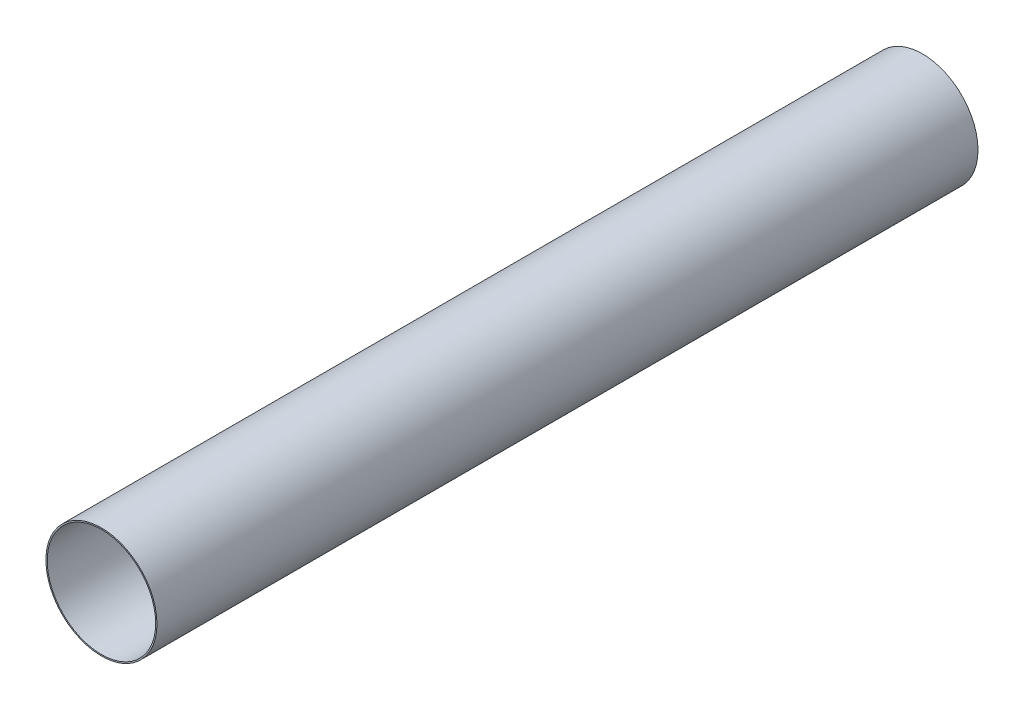
from build123d import *

# Parameters (mm, degrees)
SKETCH1_R           = 84.55
SKETCH1_R_2         = 82.55
BOSS_EXTRUDE1_DEPTH = 625


with BuildPart() as part:
    # Sketch1 → Boss-Extrude1 (new body, symmetric)
    with BuildSketch(Plane.XY):
        Circle(SKETCH1_R)
        Circle(SKETCH1_R_2, mode=Mode.SUBTRACT)
    extrude(amount=BOSS_EXTRUDE1_DEPTH, both=True)


solid = part.part
